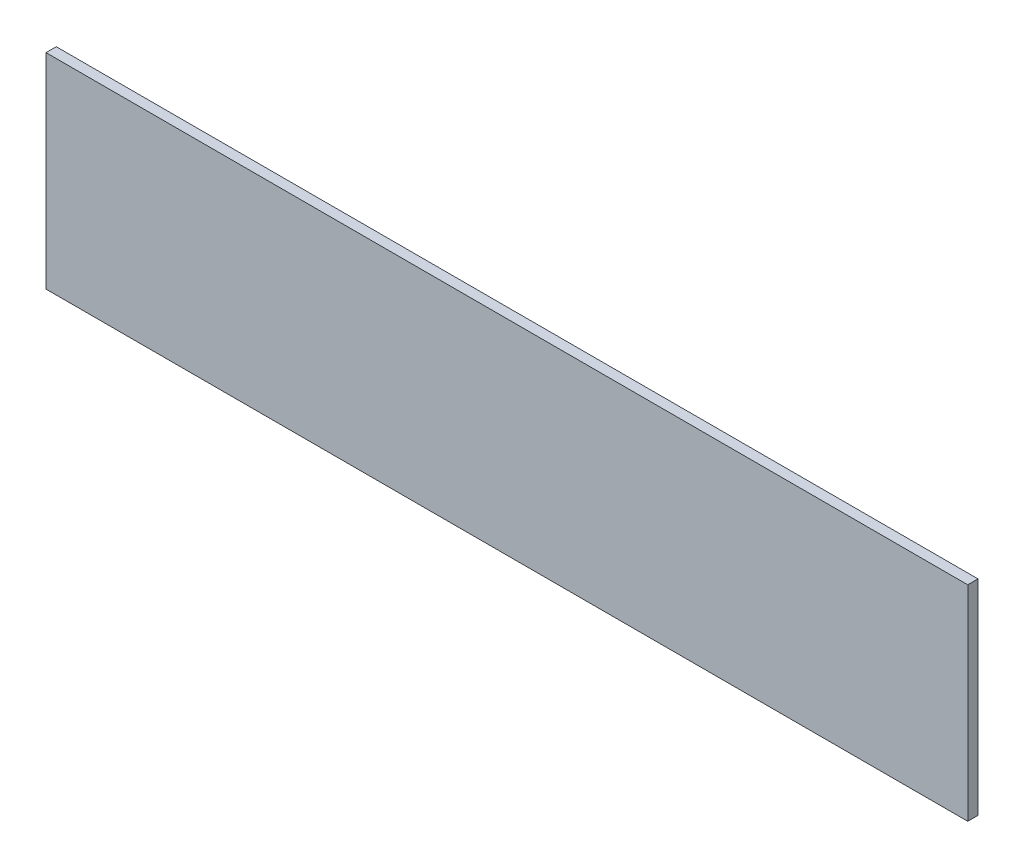
from build123d import *

# Parameters (mm, degrees)
ESQUISSE1_W        = 270
ESQUISSE1_H        = 60
BOSS_EXTRU_1_DEPTH = 3


with BuildPart() as part:
    # Esquisse1 → Boss.-Extru.1 (new body)
    with BuildSketch(Plane.XY):
        with Locations((-100.430934816, -2.280334728)):
            Rectangle(ESQUISSE1_W, ESQUISSE1_H)
    extrude(amount=BOSS_EXTRU_1_DEPTH)


solid = part.part
